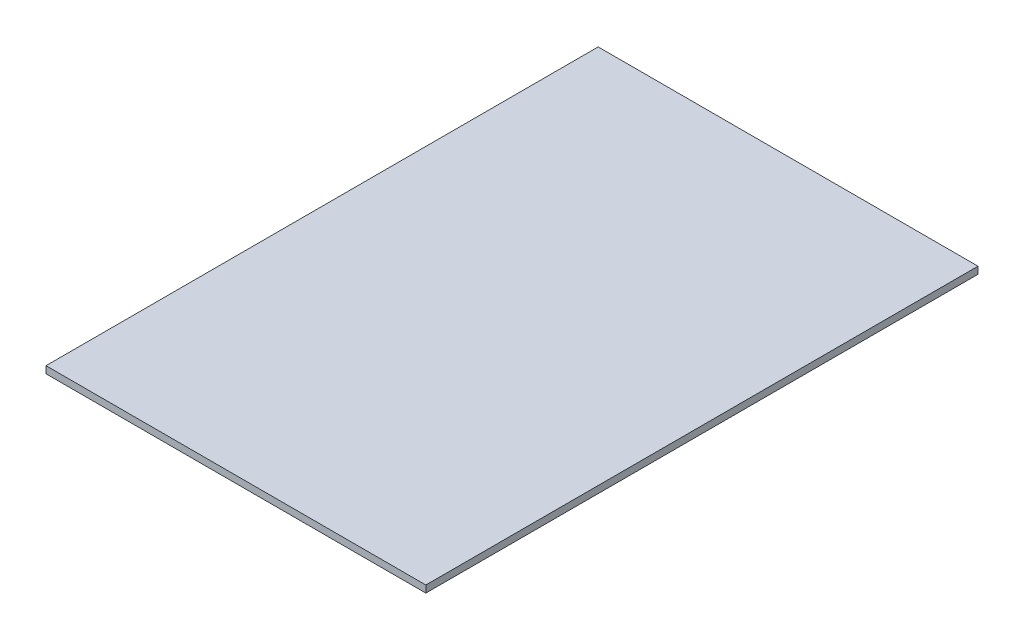
from build123d import *

# Parameters (mm, degrees)
SKETCH1_W           = 540
SKETCH1_H           = 785
BOSS_EXTRUDE1_DEPTH = 10


with BuildPart() as part:
    # Sketch1 → Boss-Extrude1 (new body)
    with BuildSketch(Plane(origin=(0, 0, 0), x_dir=(1, 0, 0), z_dir=(0, 1, 0))):
        Rectangle(SKETCH1_W, SKETCH1_H)
    extrude(amount=BOSS_EXTRUDE1_DEPTH)


solid = part.part
